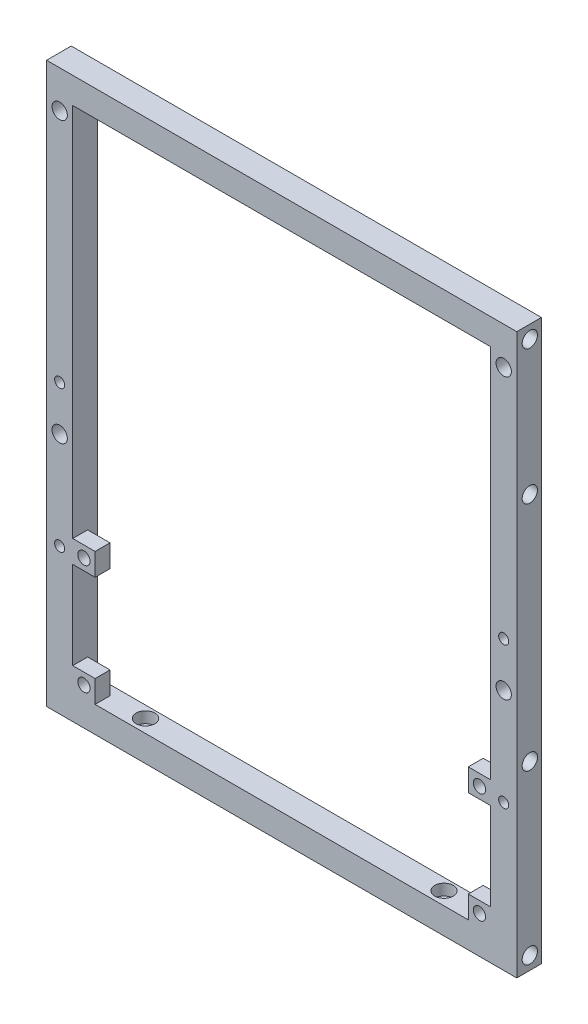
from build123d import *

# Parameters (mm, degrees)
SKETCH1_W           = 126
SKETCH1_H           = 150
SKETCH1_W_2         = 112
SKETCH1_H_2         = 136
BOSS_EXTRUDE1_DEPTH = 7
SKETCH2_R           = 2.05
CUT_EXTRUDE1_DEPTH  = 6
SKETCH3_R           = 1.35
CUT_EXTRUDE2_DEPTH  = 8
SKETCH4_R           = 2.5
CUT_EXTRUDE3_DEPTH  = 3
SKETCH5_R           = 1.35
CUT_EXTRUDE4_DEPTH  = 8
SKETCH6_R           = 2.5
CUT_EXTRUDE5_DEPTH  = 3
SKETCH7_R           = 2.05
CUT_EXTRUDE6_DEPTH  = 8
CUT_EXTRUDE7_DEPTH  = 0.2
SKETCH9_W           = 2.7
SKETCH9_H           = 2.7
CUT_EXTRUDE8_DEPTH  = 0.2
SKETCH10_W          = 6
SKETCH10_H          = 6
BOSS_EXTRUDE2_DEPTH = 4
SKETCH11_R          = 1.65
CUT_EXTRUDE9_DEPTH  = 5
CHAMFER1_SIZE       = 0.4
CHAMFER2_SIZE       = 0.4


with BuildPart() as part:
    # Sketch1 → Boss-Extrude1 (new body)
    with BuildSketch(Plane.XY):
        Rectangle(SKETCH1_W, SKETCH1_H)
        Rectangle(SKETCH1_W_2, SKETCH1_H_2, mode=Mode.SUBTRACT)
    extrude(amount=BOSS_EXTRUDE1_DEPTH)

    # Sketch2 → Cut-Extrude1 (cut)
    with BuildSketch(Plane.ZY.offset(63)):
        with Locations((3.5, -71.5)):
            Circle(SKETCH2_R)
        with Locations((3.5, 71.5)):
            Circle(SKETCH2_R)
        with Locations((3.5, 35.5)):
            Circle(SKETCH2_R)
        with Locations((3.5, -26.5)):
            Circle(SKETCH2_R)
    cut_extrude1 = extrude(amount=-CUT_EXTRUDE1_DEPTH, mode=Mode.SUBTRACT)

    # Mirror1: Cut-Extrude1 across plane
    add(cut_extrude1.mirror(Plane(origin=(0, 0, 0), x_dir=(0, 0, 1), z_dir=(1, 0, 0))), mode=Mode.SUBTRACT)

    # Sketch3 → Cut-Extrude2 (cut, through all)
    with BuildSketch(Plane(origin=(0, -68, 0), x_dir=(1, 0, 0), z_dir=(0, 1, 0))):
        with Locations((40, -3.5)):
            Circle(SKETCH3_R)
        with Locations((-40, -3.5)):
            Circle(SKETCH3_R)
    extrude(amount=-CUT_EXTRUDE2_DEPTH, mode=Mode.SUBTRACT)

    # Sketch4 → Cut-Extrude3 (cut)
    with BuildSketch(Plane(origin=(0, -68, 0), x_dir=(1, 0, 0), z_dir=(0, 1, 0))):
        with Locations((40, -3.5)):
            Circle(SKETCH4_R)
        with Locations((-40, -3.5)):
            Circle(SKETCH4_R)
    extrude(amount=-CUT_EXTRUDE3_DEPTH, mode=Mode.SUBTRACT)

    # Sketch5 → Cut-Extrude4 (cut, through all)
    with BuildSketch(Plane(origin=(0, 0, 0), x_dir=(-1, 0, 0), z_dir=(0, 0, -1))):
        with Locations((-59.5, 2)):
            Circle(SKETCH5_R)
        with Locations((59.5, 2)):
            Circle(SKETCH5_R)
        with Locations((-59.5, -36)):
            Circle(SKETCH5_R)
        with Locations((59.5, -36)):
            Circle(SKETCH5_R)
    extrude(amount=-CUT_EXTRUDE4_DEPTH, mode=Mode.SUBTRACT)

    # Sketch6 → Cut-Extrude5 (cut)
    with BuildSketch(Plane(origin=(0, 0, 0), x_dir=(-1, 0, 0), z_dir=(0, 0, -1))):
        with Locations((-59.5, 2)):
            Circle(SKETCH6_R)
        with Locations((59.5, 2)):
            Circle(SKETCH6_R)
        with Locations((-59.5, -36)):
            Circle(SKETCH6_R)
        with Locations((59.5, -36)):
            Circle(SKETCH6_R)
    extrude(amount=-CUT_EXTRUDE5_DEPTH, mode=Mode.SUBTRACT)

    # Sketch7 → Cut-Extrude6 (cut, through all)
    with BuildSketch(Plane(origin=(0, 0, 0), x_dir=(-1, 0, 0), z_dir=(0, 0, -1))):
        with Locations((-59.5, 65)):
            Circle(SKETCH7_R)
        with Locations((-59.5, -10)):
            Circle(SKETCH7_R)
    cut_extrude6 = extrude(amount=-CUT_EXTRUDE6_DEPTH, mode=Mode.SUBTRACT)

    # Mirror2: Cut-Extrude6 across plane
    add(cut_extrude6.mirror(Plane(origin=(0, 0, 0), x_dir=(0, 0, 1), z_dir=(1, 0, 0))), mode=Mode.SUBTRACT)

    # Sketch8 → Cut-Extrude7 (cut)
    with BuildSketch(Plane(origin=(0, 0, 3), x_dir=(-1, 0, 0), z_dir=(0, 0, -1))):
        with BuildLine():
            Line((-60.85, -0.104162541), (-60.85, 4.104162541))
            ThreePointArc((-60.85, 4.104162541), (-59.5, 4.5), (-58.15, 4.104162541))
            Line((-58.15, 4.104162541), (-58.15, -0.104162541))
            ThreePointArc((-58.15, -0.104162541), (-59.5, -0.5), (-60.85, -0.104162541))
        make_face()
        with BuildLine():
            Line((-60.85, -38.104162541), (-60.85, -33.895837459))
            ThreePointArc((-60.85, -33.895837459), (-59.5, -33.5), (-58.15, -33.895837459))
            Line((-58.15, -33.895837459), (-58.15, -38.104162541))
            ThreePointArc((-58.15, -38.104162541), (-59.5, -38.5), (-60.85, -38.104162541))
        make_face()
    cut_extrude7 = extrude(amount=-CUT_EXTRUDE7_DEPTH, mode=Mode.SUBTRACT)

    # Sketch9 → Cut-Extrude8 (cut)
    with BuildSketch(Plane(origin=(0, 0, 3.2), x_dir=(-1, 0, 0), z_dir=(0, 0, -1))):
        with Locations((-59.5, 2)):
            Rectangle(SKETCH9_W, SKETCH9_H)
        with Locations((-59.5, -36)):
            Rectangle(SKETCH9_W, SKETCH9_H)
    cut_extrude8 = extrude(amount=-CUT_EXTRUDE8_DEPTH, mode=Mode.SUBTRACT)

    # Mirror3: Cut-Extrude7, Cut-Extrude8 across plane
    add(cut_extrude7.mirror(Plane(origin=(0, 0, 0), x_dir=(0, 0, 1), z_dir=(1, 0, 0))), mode=Mode.SUBTRACT)
    add(cut_extrude8.mirror(Plane(origin=(0, 0, 0), x_dir=(0, 0, 1), z_dir=(1, 0, 0))), mode=Mode.SUBTRACT)

    # Sketch10 → Boss-Extrude2 (add)
    with BuildSketch(Plane.XY.offset(7)):
        with Locations((53, -65)):
            Rectangle(SKETCH10_W, SKETCH10_H)
        with Locations((53, -35.5)):
            Rectangle(SKETCH10_W, SKETCH10_H)
    boss_extrude2 = extrude(amount=-BOSS_EXTRUDE2_DEPTH)

    # Sketch11 → Cut-Extrude9 (cut, through all)
    with BuildSketch(Plane(origin=(0, 0, 3), x_dir=(-1, 0, 0), z_dir=(0, 0, -1))):
        with Locations((-53, -35.5)):
            Circle(SKETCH11_R)
        with Locations((-53, -65)):
            Circle(SKETCH11_R)
    cut_extrude9 = extrude(amount=-CUT_EXTRUDE9_DEPTH, mode=Mode.SUBTRACT)

    # Mirror4: Boss-Extrude2, Cut-Extrude9 across plane
    add(boss_extrude2.mirror(Plane(origin=(0, 0, 0), x_dir=(0, 0, 1), z_dir=(1, 0, 0))))
    add(cut_extrude9.mirror(Plane(origin=(0, 0, 0), x_dir=(0, 0, 1), z_dir=(1, 0, 0))), mode=Mode.SUBTRACT)

    # Chamfer1
    chamfer1_edges = [part.edges().sort_by_distance(p)[0] for p in [
        (56, 0, 0),
        (0, 68, 0),
        (-56, 0, 0),
        (0, -68, 0),
    ]]
    chamfer(chamfer1_edges, length=CHAMFER1_SIZE)

    # Chamfer2
    chamfer2_edges = [part.edges().sort_by_distance(p)[0] for p in [
        (0, -75, 0),
        (-63, 0, 0),
        (0, 75, 0),
        (63, 0, 0),
    ]]
    chamfer(chamfer2_edges, length=CHAMFER2_SIZE)


solid = part.part
